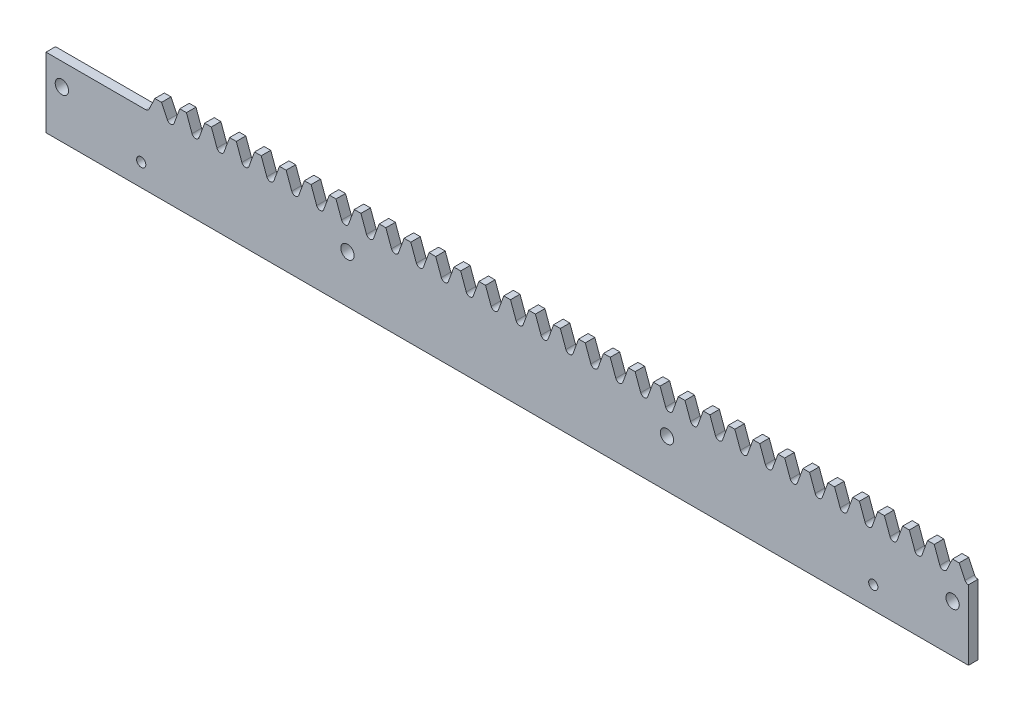
from build123d import *

# Parameters (mm, degrees)
ESQUISSE1_R             = 2.1
EXTRUSION1_DEPTH        = 3
ESQUISSE4_R             = 1.45
ENL_V_MAT_EXTRU_2_DEPTH = 4


with BuildPart() as part:
    # Esquisse1 → Extrusion1 (new body)
    with BuildSketch(Plane.XY):
        with BuildLine():
            Line((-11.780972452, 22), (19.634954087, 22))
            ThreePointArc((19.634954087, 22), (20.207764851, 22.148388876), (20.636482657, 22.556227657))
            Line((20.636482657, 22.556227657), (22.508375082, 26.5))
            Line((22.508375082, 26.5), (24.615514728, 26.5))
            Line((24.615514728, 26.5), (26.487407153, 22.556227657))
            ThreePointArc((26.487407153, 22.556227657), (26.916124959, 22.148388876), (27.488935722, 22))
            ThreePointArc((27.488935722, 22), (28.165627746, 22.213360175), (28.597563031, 22.776269199))
            Line((28.597563031, 22.776269199), (30.362356717, 27.625))
            Line((30.362356717, 27.625), (32.469496363, 27.625))
            Line((32.469496363, 27.625), (34.234290049, 22.776269199))
            ThreePointArc((34.234290049, 22.776269199), (34.666225334, 22.213360175), (35.342917357, 22))
            ThreePointArc((35.342917357, 22), (36.019609381, 22.213360175), (36.451544666, 22.776269199))
            Line((36.451544666, 22.776269199), (38.216338352, 27.625))
            Line((38.216338352, 27.625), (40.323477998, 27.625))
            Line((40.323477998, 27.625), (42.088271684, 22.776269199))
            ThreePointArc((42.088271684, 22.776269199), (42.520206969, 22.213360175), (43.196898992, 22))
            ThreePointArc((43.196898992, 22), (43.873591016, 22.213360175), (44.305526301, 22.776269199))
            Line((44.305526301, 22.776269199), (46.070319987, 27.625))
            Line((46.070319987, 27.625), (48.177459633, 27.625))
            Line((48.177459633, 27.625), (49.942253319, 22.776269199))
            ThreePointArc((49.942253319, 22.776269199), (50.374188604, 22.213360175), (51.050880627, 22))
            ThreePointArc((51.050880627, 22), (51.727572651, 22.213360175), (52.159507936, 22.776269199))
            Line((52.159507936, 22.776269199), (53.924301622, 27.625))
            Line((53.924301622, 27.625), (56.031441268, 27.625))
            Line((56.031441268, 27.625), (57.796234954, 22.776269199))
            ThreePointArc((57.796234954, 22.776269199), (58.228170239, 22.213360175), (58.904862262, 22))
            ThreePointArc((58.904862262, 22), (59.581554286, 22.213360175), (60.013489571, 22.776269199))
            Line((60.013489571, 22.776269199), (61.778283257, 27.625))
            Line((61.778283257, 27.625), (63.885422903, 27.625))
            Line((63.885422903, 27.625), (65.650216589, 22.776269199))
            ThreePointArc((65.650216589, 22.776269199), (66.082151874, 22.213360175), (66.758843897, 22))
            ThreePointArc((66.758843897, 22), (67.435535921, 22.213360175), (67.867471206, 22.776269199))
            Line((67.867471206, 22.776269199), (69.632264892, 27.625))
            Line((69.632264892, 27.625), (71.739404538, 27.625))
            Line((71.739404538, 27.625), (73.504198224, 22.776269199))
            ThreePointArc((73.504198224, 22.776269199), (73.936133509, 22.213360175), (74.612825532, 22))
            ThreePointArc((74.612825532, 22), (75.289517556, 22.213360175), (75.721452841, 22.776269199))
            Line((75.721452841, 22.776269199), (77.486246527, 27.625))
            Line((77.486246527, 27.625), (79.593386173, 27.625))
            Line((79.593386173, 27.625), (81.358179859, 22.776269199))
            ThreePointArc((81.358179859, 22.776269199), (81.790115144, 22.213360175), (82.466807167, 22))
            ThreePointArc((82.466807167, 22), (83.143499191, 22.213360175), (83.575434476, 22.776269199))
            Line((83.575434476, 22.776269199), (85.340228162, 27.625))
            Line((85.340228162, 27.625), (87.447367808, 27.625))
            Line((87.447367808, 27.625), (89.212161494, 22.776269199))
            ThreePointArc((89.212161494, 22.776269199), (89.644096779, 22.213360175), (90.320788802, 22))
            ThreePointArc((90.320788802, 22), (90.997480826, 22.213360175), (91.429416111, 22.776269199))
            Line((91.429416111, 22.776269199), (93.194209797, 27.625))
            Line((93.194209797, 27.625), (95.301349443, 27.625))
            Line((95.301349443, 27.625), (97.066143129, 22.776269199))
            ThreePointArc((97.066143129, 22.776269199), (97.498078414, 22.213360175), (98.174770437, 22))
            ThreePointArc((98.174770437, 22), (98.851462461, 22.213360175), (99.283397746, 22.776269199))
            Line((99.283397746, 22.776269199), (101.048191432, 27.625))
            Line((101.048191432, 27.625), (103.155331078, 27.625))
            Line((103.155331078, 27.625), (104.920124764, 22.776269199))
            ThreePointArc((104.920124764, 22.776269199), (105.352060049, 22.213360175), (106.028752072, 22))
            ThreePointArc((106.028752072, 22), (106.705444096, 22.213360175), (107.137379381, 22.776269199))
            Line((107.137379381, 22.776269199), (108.902173067, 27.625))
            Line((108.902173067, 27.625), (111.009312713, 27.625))
            Line((111.009312713, 27.625), (112.774106399, 22.776269199))
            ThreePointArc((112.774106399, 22.776269199), (113.206041684, 22.213360175), (113.882733707, 22))
            ThreePointArc((113.882733707, 22), (114.559425731, 22.213360175), (114.991361016, 22.776269199))
            Line((114.991361016, 22.776269199), (116.756154702, 27.625))
            Line((116.756154702, 27.625), (118.863294348, 27.625))
            Line((118.863294348, 27.625), (120.628088034, 22.776269199))
            ThreePointArc((120.628088034, 22.776269199), (121.060023319, 22.213360175), (121.736715342, 22))
            ThreePointArc((121.736715342, 22), (122.413407366, 22.213360175), (122.845342651, 22.776269199))
            Line((122.845342651, 22.776269199), (124.610136337, 27.625))
            Line((124.610136337, 27.625), (126.717275983, 27.625))
            Line((126.717275983, 27.625), (128.482069669, 22.776269199))
            ThreePointArc((128.482069669, 22.776269199), (128.914004954, 22.213360175), (129.590696977, 22))
            ThreePointArc((129.590696977, 22), (130.267389001, 22.213360175), (130.699324286, 22.776269199))
            Line((130.699324286, 22.776269199), (132.464117972, 27.625))
            Line((132.464117972, 27.625), (134.571257618, 27.625))
            Line((134.571257618, 27.625), (136.336051304, 22.776269199))
            ThreePointArc((136.336051304, 22.776269199), (136.767986589, 22.213360175), (137.444678612, 22))
            ThreePointArc((137.444678612, 22), (138.121370636, 22.213360175), (138.553305921, 22.776269199))
            Line((138.553305921, 22.776269199), (140.318099607, 27.625))
            Line((140.318099607, 27.625), (142.425239253, 27.625))
            Line((142.425239253, 27.625), (144.190032939, 22.776269199))
            ThreePointArc((144.190032939, 22.776269199), (144.621968224, 22.213360175), (145.298660247, 22))
            ThreePointArc((145.298660247, 22), (145.975352271, 22.213360175), (146.407287556, 22.776269199))
            Line((146.407287556, 22.776269199), (148.172081242, 27.625))
            Line((148.172081242, 27.625), (150.279220888, 27.625))
            Line((150.279220888, 27.625), (152.044014574, 22.776269199))
            ThreePointArc((152.044014574, 22.776269199), (152.475949859, 22.213360175), (153.152641882, 22))
            ThreePointArc((153.152641882, 22), (153.829333906, 22.213360175), (154.261269191, 22.776269199))
            Line((154.261269191, 22.776269199), (156.026062877, 27.625))
            Line((156.026062877, 27.625), (158.133202523, 27.625))
            Line((158.133202523, 27.625), (159.897996209, 22.776269199))
            ThreePointArc((159.897996209, 22.776269199), (160.329931494, 22.213360175), (161.006623517, 22))
            ThreePointArc((161.006623517, 22), (161.683315541, 22.213360175), (162.115250826, 22.776269199))
            Line((162.115250826, 22.776269199), (163.880044512, 27.625))
            Line((163.880044512, 27.625), (165.987184158, 27.625))
            Line((165.987184158, 27.625), (167.751977844, 22.776269199))
            ThreePointArc((167.751977844, 22.776269199), (168.183913129, 22.213360175), (168.860605152, 22))
            ThreePointArc((168.860605152, 22), (169.537297176, 22.213360175), (169.969232461, 22.776269199))
            Line((169.969232461, 22.776269199), (171.734026147, 27.625))
            Line((171.734026147, 27.625), (173.841165793, 27.625))
            Line((173.841165793, 27.625), (175.605959479, 22.776269199))
            ThreePointArc((175.605959479, 22.776269199), (176.037894764, 22.213360175), (176.714586787, 22))
            ThreePointArc((176.714586787, 22), (177.391278811, 22.213360175), (177.823214096, 22.776269199))
            Line((177.823214096, 22.776269199), (179.588007782, 27.625))
            Line((179.588007782, 27.625), (181.695147428, 27.625))
            Line((181.695147428, 27.625), (183.459941114, 22.776269199))
            ThreePointArc((183.459941114, 22.776269199), (183.891876399, 22.213360175), (184.568568422, 22))
            ThreePointArc((184.568568422, 22), (185.245260446, 22.213360175), (185.677195731, 22.776269199))
            Line((185.677195731, 22.776269199), (187.441989417, 27.625))
            Line((187.441989417, 27.625), (189.549129063, 27.625))
            Line((189.549129063, 27.625), (191.313922749, 22.776269199))
            ThreePointArc((191.313922749, 22.776269199), (191.745858034, 22.213360175), (192.422550057, 22))
            ThreePointArc((192.422550057, 22), (193.099242081, 22.213360175), (193.531177366, 22.776269199))
            Line((193.531177366, 22.776269199), (195.295971052, 27.625))
            Line((195.295971052, 27.625), (197.403110698, 27.625))
            Line((197.403110698, 27.625), (199.167904384, 22.776269199))
            ThreePointArc((199.167904384, 22.776269199), (199.599839669, 22.213360175), (200.276531692, 22))
            ThreePointArc((200.276531692, 22), (200.953223716, 22.213360175), (201.385159001, 22.776269199))
            Line((201.385159001, 22.776269199), (203.149952687, 27.625))
            Line((203.149952687, 27.625), (205.257092333, 27.625))
            Line((205.257092333, 27.625), (207.021886019, 22.776269199))
            ThreePointArc((207.021886019, 22.776269199), (207.453821304, 22.213360175), (208.130513327, 22))
            ThreePointArc((208.130513327, 22), (208.807205351, 22.213360175), (209.239140636, 22.776269199))
            Line((209.239140636, 22.776269199), (211.003934322, 27.625))
            Line((211.003934322, 27.625), (213.111073968, 27.625))
            Line((213.111073968, 27.625), (214.875867654, 22.776269199))
            ThreePointArc((214.875867654, 22.776269199), (215.307802939, 22.213360175), (215.984494962, 22))
            ThreePointArc((215.984494962, 22), (216.661186986, 22.213360175), (217.093122271, 22.776269199))
            Line((217.093122271, 22.776269199), (218.857915957, 27.625))
            Line((218.857915957, 27.625), (220.965055603, 27.625))
            Line((220.965055603, 27.625), (222.729849289, 22.776269199))
            ThreePointArc((222.729849289, 22.776269199), (223.161784574, 22.213360175), (223.838476597, 22))
            ThreePointArc((223.838476597, 22), (224.515168621, 22.213360175), (224.947103906, 22.776269199))
            Line((224.947103906, 22.776269199), (226.711897592, 27.625))
            Line((226.711897592, 27.625), (228.819037238, 27.625))
            Line((228.819037238, 27.625), (230.583830924, 22.776269199))
            ThreePointArc((230.583830924, 22.776269199), (231.015766209, 22.213360175), (231.692458232, 22))
            ThreePointArc((231.692458232, 22), (232.369150256, 22.213360175), (232.801085541, 22.776269199))
            Line((232.801085541, 22.776269199), (234.565879227, 27.625))
            Line((234.565879227, 27.625), (236.673018873, 27.625))
            Line((236.673018873, 27.625), (238.437812559, 22.776269199))
            ThreePointArc((238.437812559, 22.776269199), (238.869747844, 22.213360175), (239.546439867, 22))
            ThreePointArc((239.546439867, 22), (240.223131891, 22.213360175), (240.655067176, 22.776269199))
            Line((240.655067176, 22.776269199), (242.419860862, 27.625))
            Line((242.419860862, 27.625), (244.527000508, 27.625))
            Line((244.527000508, 27.625), (246.291794194, 22.776269199))
            ThreePointArc((246.291794194, 22.776269199), (246.723729479, 22.213360175), (247.400421502, 22))
            ThreePointArc((247.400421502, 22), (248.077113526, 22.213360175), (248.509048811, 22.776269199))
            Line((248.509048811, 22.776269199), (250.273842497, 27.625))
            Line((250.273842497, 27.625), (252.380982143, 27.625))
            Line((252.380982143, 27.625), (254.145775829, 22.776269199))
            ThreePointArc((254.145775829, 22.776269199), (254.577711114, 22.213360175), (255.254403137, 22))
            ThreePointArc((255.254403137, 22), (255.931095161, 22.213360175), (256.363030446, 22.776269199))
            Line((256.363030446, 22.776269199), (258.127824132, 27.625))
            Line((258.127824132, 27.625), (260.234963778, 27.625))
            Line((260.234963778, 27.625), (261.999757464, 22.776269199))
            ThreePointArc((261.999757464, 22.776269199), (262.431692749, 22.213360175), (263.108384772, 22))
            ThreePointArc((263.108384772, 22), (263.785076796, 22.213360175), (264.217012081, 22.776269199))
            Line((264.217012081, 22.776269199), (265.981805767, 27.625))
            Line((265.981805767, 27.625), (268.088945413, 27.625))
            Line((268.088945413, 27.625), (269.853739099, 22.776269199))
            ThreePointArc((269.853739099, 22.776269199), (270.285674384, 22.213360175), (270.962366407, 22))
            ThreePointArc((270.962366407, 22), (271.572652612, 22.17011153), (272.006944946, 22.631389486))
            Line((272.006944946, 22.631389486), (273.835787402, 26.5))
            Line((273.835787402, 26.5), (275.942927048, 26.5))
            Line((275.942927048, 26.5), (277.771769504, 22.631389486))
            ThreePointArc((277.771769504, 22.631389486), (278.231733017, 22.155033667), (278.875867654, 22.001502336))
            Line((278.875867654, 22.001502336), (278.875867654, 0))
            Line((278.875867654, 0), (-11.780972452, 0))
            Line((-11.780972452, 0), (-11.780972452, 22))
        make_face()
        with Locations((183.875867654, 15)):
            Circle(ESQUISSE1_R, mode=Mode.SUBTRACT)
        with Locations((83.219027548, 15)):
            Circle(ESQUISSE1_R, mode=Mode.SUBTRACT)
        with Locations((-6.780972452, 15)):
            Circle(ESQUISSE1_R, mode=Mode.SUBTRACT)
        with Locations((273.875867654, 15)):
            Circle(ESQUISSE1_R, mode=Mode.SUBTRACT)
    extrude(amount=EXTRUSION1_DEPTH)

    # Esquisse4 → Enlèv. mat.-Extru.2 (cut, through all)
    with BuildSketch(Plane.XY.offset(3)):
        with Locations((18.219027547, 7)):
            Circle(ESQUISSE4_R)
        with Locations((248.875867654, 7)):
            Circle(ESQUISSE4_R)
    extrude(amount=-ENL_V_MAT_EXTRU_2_DEPTH, mode=Mode.SUBTRACT)


solid = part.part
